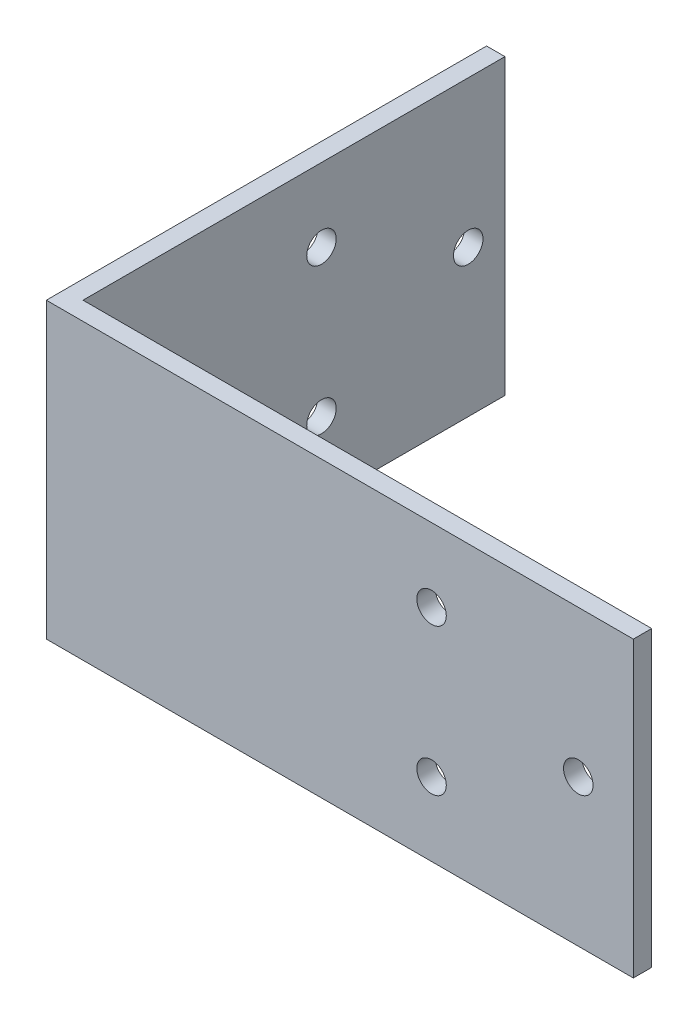
from build123d import *

# Parameters (mm, degrees)
BOSS_EXTRUDE1_DEPTH = 50.8
SKETCH2_R           = 2.5527
CUT_EXTRUDE1_DEPTH  = 50.8
SKETCH3_R           = 2.5527
CUT_EXTRUDE2_DEPTH  = 50.8


with BuildPart() as part:
    # Sketch1 → Boss-Extrude1 (new body)
    with BuildSketch(Plane(origin=(0, 0, 0), x_dir=(1, 0, 0), z_dir=(0, 1, 0))):
        Polygon((0, 0), (0, 76.2), (3.175, 76.2), (3.175, 3.175), (101.6, 3.175), (101.6, 0), align=None)
    extrude(amount=BOSS_EXTRUDE1_DEPTH)

    # Sketch2 → Cut-Extrude1 (cut)
    with BuildSketch(Plane.XY):
        with Locations((92.075, 25.4)):
            Circle(SKETCH2_R)
        with Locations((66.675, 38.1)):
            Circle(SKETCH2_R)
        with Locations((66.675, 12.7)):
            Circle(SKETCH2_R)
    extrude(amount=-CUT_EXTRUDE1_DEPTH, mode=Mode.SUBTRACT)

    # Sketch3 → Cut-Extrude2 (cut)
    with BuildSketch(Plane.ZY):
        with Locations((-69.85, 25.4)):
            Circle(SKETCH3_R)
        with Locations((-44.45, 38.1)):
            Circle(SKETCH3_R)
        with Locations((-44.45, 12.7)):
            Circle(SKETCH3_R)
    extrude(amount=-CUT_EXTRUDE2_DEPTH, mode=Mode.SUBTRACT)


solid = part.part
